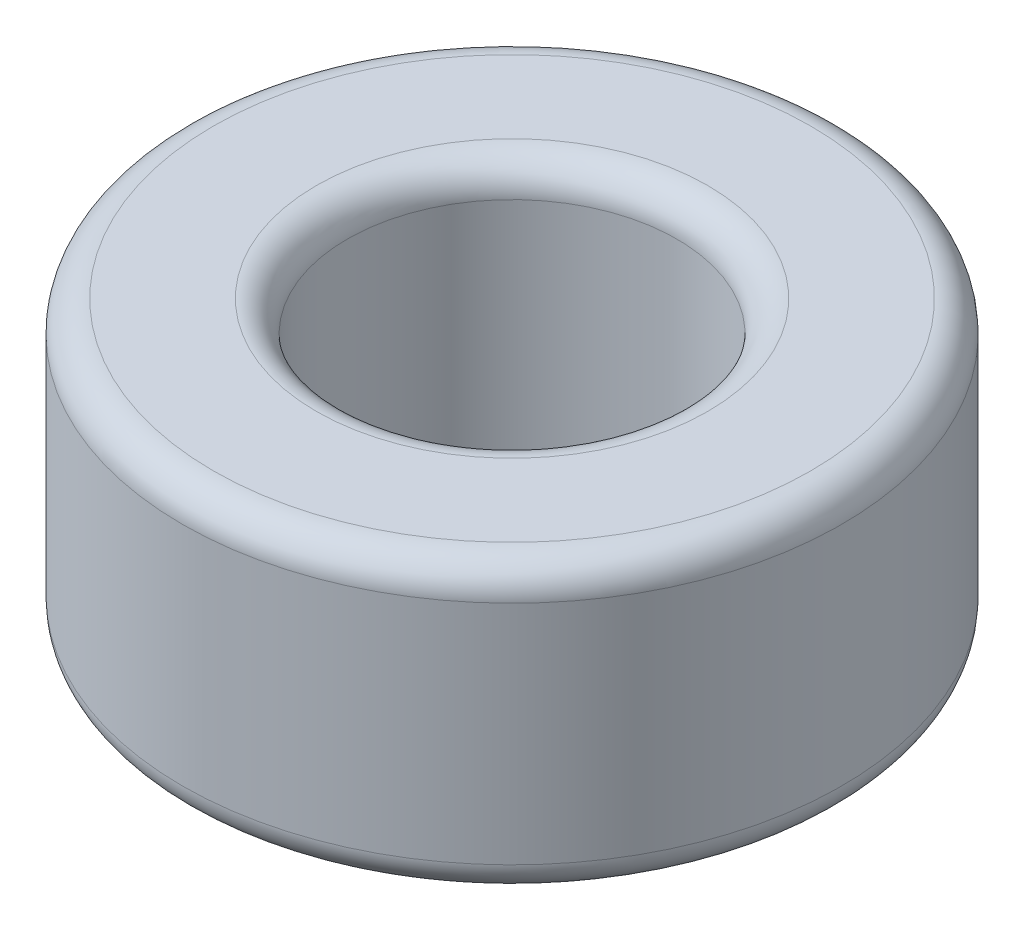
from build123d import *

# Parameters (mm, degrees)
SKETCH1_R               = 203.2
BOSS_EXTRUDE1_DEPTH     = 177.8
SKETCH2_R               = 101.6
CUT_EXTRUDE1_DEPTH      = 1
CUT_EXTRUDE1_DEPTH_BACK = 178.8
FILLET1_R               = 19.05
SHELL1_T                = 12.7


with BuildPart() as part:
    # Sketch1 → Boss-Extrude1 (new body)
    with BuildSketch(Plane(origin=(0, 0, 0), x_dir=(1, 0, 0), z_dir=(0, 1, 0))):
        Circle(SKETCH1_R)
    extrude(amount=BOSS_EXTRUDE1_DEPTH)

    # Sketch2 → Cut-Extrude1 (cut, two sides)
    with BuildSketch(Plane.XZ) as cut_extrude1_sk:
        Circle(SKETCH2_R)
    extrude(amount=CUT_EXTRUDE1_DEPTH, mode=Mode.SUBTRACT)
    extrude(cut_extrude1_sk.sketch, amount=-CUT_EXTRUDE1_DEPTH_BACK, mode=Mode.SUBTRACT)

    # Fillet1
    fillet1_edges = [part.edges().sort_by_distance(p)[0] for p in [
        (-203.2, 0, 0),
        (-203.2, 177.8, 0),
        (-101.6, 177.8, 0),
        (-101.6, 0, 0),
    ]]
    fillet(fillet1_edges, radius=FILLET1_R)

    # Shell1 (no face opened: a closed hollow body)
    add(offset(amount=-SHELL1_T, mode=Mode.PRIVATE), mode=Mode.SUBTRACT)


solid = part.part
